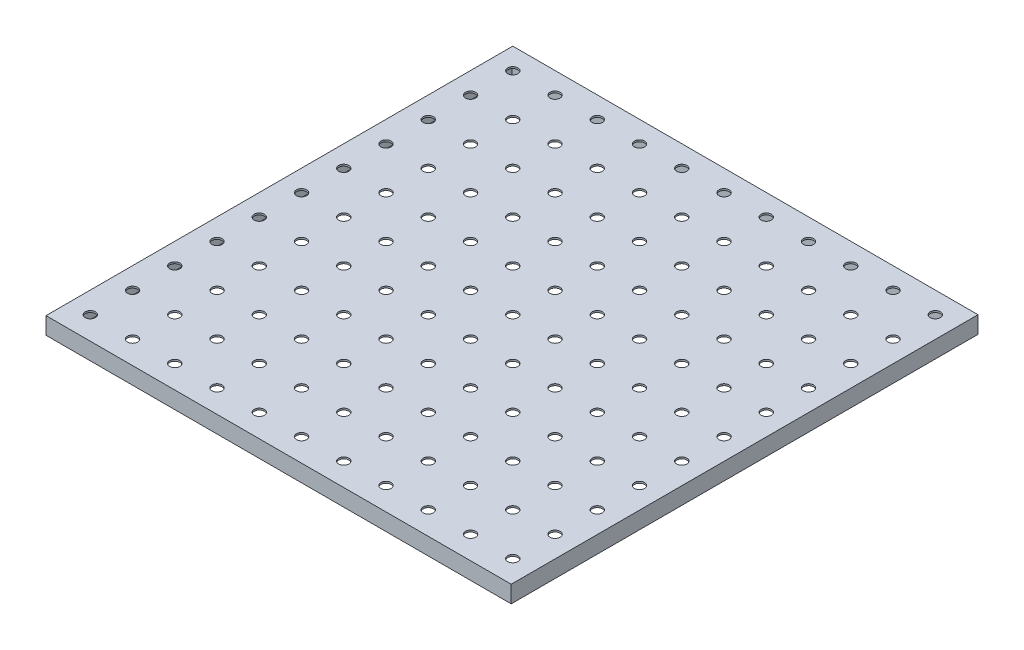
from build123d import *

# Parameters (mm, degrees)
SKETCH1_W           = 273.071306992
SKETCH1_H           = 273.996798624
SKETCH1_R           = 3
BOSS_EXTRUDE1_DEPTH = 10
SKETCH2_W           = 263.071306992
SKETCH2_H           = 263.071306992
CUT_EXTRUDE1_DEPTH  = 9


with BuildPart() as part:
    # Sketch1 → Boss-Extrude1 (new body)
    with BuildSketch(Plane(origin=(0, 0, 0), x_dir=(1, 0, 0), z_dir=(0, 1, 0))):
        Rectangle(SKETCH1_W, SKETCH1_H)
        with Locations((-124.000653496, 124.463399312)):
            Circle(SKETCH1_R, mode=Mode.SUBTRACT)
        with Locations((-99.200653496, 124.463399312)):
            Circle(SKETCH1_R, mode=Mode.SUBTRACT)
        with Locations((-74.400653496, 124.463399312)):
            Circle(SKETCH1_R, mode=Mode.SUBTRACT)
        with Locations((-49.600653496, 124.463399312)):
            Circle(SKETCH1_R, mode=Mode.SUBTRACT)
        with Locations((-24.800653496, 124.463399312)):
            Circle(SKETCH1_R, mode=Mode.SUBTRACT)
        with Locations((-0.000653496, 124.463399312)):
            Circle(SKETCH1_R, mode=Mode.SUBTRACT)
        with Locations((24.799346504, 124.463399312)):
            Circle(SKETCH1_R, mode=Mode.SUBTRACT)
        with Locations((49.599346504, 124.463399312)):
            Circle(SKETCH1_R, mode=Mode.SUBTRACT)
        with Locations((74.399346504, 124.463399312)):
            Circle(SKETCH1_R, mode=Mode.SUBTRACT)
        with Locations((99.199346504, 124.463399312)):
            Circle(SKETCH1_R, mode=Mode.SUBTRACT)
        with Locations((123.999346504, 124.463399312)):
            Circle(SKETCH1_R, mode=Mode.SUBTRACT)
        with Locations((-99.200653496, 99.663399312)):
            Circle(SKETCH1_R, mode=Mode.SUBTRACT)
        with Locations((-74.400653496, 99.663399312)):
            Circle(SKETCH1_R, mode=Mode.SUBTRACT)
        with Locations((-49.600653496, 99.663399312)):
            Circle(SKETCH1_R, mode=Mode.SUBTRACT)
        with Locations((-24.800653496, 99.663399312)):
            Circle(SKETCH1_R, mode=Mode.SUBTRACT)
        with Locations((-0.000653496, 99.663399312)):
            Circle(SKETCH1_R, mode=Mode.SUBTRACT)
        with Locations((24.799346504, 99.663399312)):
            Circle(SKETCH1_R, mode=Mode.SUBTRACT)
        with Locations((49.599346504, 99.663399312)):
            Circle(SKETCH1_R, mode=Mode.SUBTRACT)
        with Locations((74.399346504, 99.663399312)):
            Circle(SKETCH1_R, mode=Mode.SUBTRACT)
        with Locations((99.199346504, 99.663399312)):
            Circle(SKETCH1_R, mode=Mode.SUBTRACT)
        with Locations((123.999346504, 99.663399312)):
            Circle(SKETCH1_R, mode=Mode.SUBTRACT)
        with Locations((-99.200653496, 74.863399312)):
            Circle(SKETCH1_R, mode=Mode.SUBTRACT)
        with Locations((-74.400653496, 74.863399312)):
            Circle(SKETCH1_R, mode=Mode.SUBTRACT)
        with Locations((-49.600653496, 74.863399312)):
            Circle(SKETCH1_R, mode=Mode.SUBTRACT)
        with Locations((-24.800653496, 74.863399312)):
            Circle(SKETCH1_R, mode=Mode.SUBTRACT)
        with Locations((-0.000653496, 74.863399312)):
            Circle(SKETCH1_R, mode=Mode.SUBTRACT)
        with Locations((24.799346504, 74.863399312)):
            Circle(SKETCH1_R, mode=Mode.SUBTRACT)
        with Locations((49.599346504, 74.863399312)):
            Circle(SKETCH1_R, mode=Mode.SUBTRACT)
        with Locations((74.399346504, 74.863399312)):
            Circle(SKETCH1_R, mode=Mode.SUBTRACT)
        with Locations((99.199346504, 74.863399312)):
            Circle(SKETCH1_R, mode=Mode.SUBTRACT)
        with Locations((123.999346504, 74.863399312)):
            Circle(SKETCH1_R, mode=Mode.SUBTRACT)
        with Locations((-99.200653496, 50.063399312)):
            Circle(SKETCH1_R, mode=Mode.SUBTRACT)
        with Locations((-74.400653496, 50.063399312)):
            Circle(SKETCH1_R, mode=Mode.SUBTRACT)
        with Locations((-49.600653496, 50.063399312)):
            Circle(SKETCH1_R, mode=Mode.SUBTRACT)
        with Locations((-24.800653496, 50.063399312)):
            Circle(SKETCH1_R, mode=Mode.SUBTRACT)
        with Locations((-0.000653496, 50.063399312)):
            Circle(SKETCH1_R, mode=Mode.SUBTRACT)
        with Locations((24.799346504, 50.063399312)):
            Circle(SKETCH1_R, mode=Mode.SUBTRACT)
        with Locations((49.599346504, 50.063399312)):
            Circle(SKETCH1_R, mode=Mode.SUBTRACT)
        with Locations((74.399346504, 50.063399312)):
            Circle(SKETCH1_R, mode=Mode.SUBTRACT)
        with Locations((99.199346504, 50.063399312)):
            Circle(SKETCH1_R, mode=Mode.SUBTRACT)
        with Locations((123.999346504, 50.063399312)):
            Circle(SKETCH1_R, mode=Mode.SUBTRACT)
        with Locations((-99.200653496, 25.263399312)):
            Circle(SKETCH1_R, mode=Mode.SUBTRACT)
        with Locations((-74.400653496, 25.263399312)):
            Circle(SKETCH1_R, mode=Mode.SUBTRACT)
        with Locations((-49.600653496, 25.263399312)):
            Circle(SKETCH1_R, mode=Mode.SUBTRACT)
        with Locations((-24.800653496, 25.263399312)):
            Circle(SKETCH1_R, mode=Mode.SUBTRACT)
        with Locations((-0.000653496, 25.263399312)):
            Circle(SKETCH1_R, mode=Mode.SUBTRACT)
        with Locations((24.799346504, 25.263399312)):
            Circle(SKETCH1_R, mode=Mode.SUBTRACT)
        with Locations((49.599346504, 25.263399312)):
            Circle(SKETCH1_R, mode=Mode.SUBTRACT)
        with Locations((74.399346504, 25.263399312)):
            Circle(SKETCH1_R, mode=Mode.SUBTRACT)
        with Locations((99.199346504, 25.263399312)):
            Circle(SKETCH1_R, mode=Mode.SUBTRACT)
        with Locations((123.999346504, 25.263399312)):
            Circle(SKETCH1_R, mode=Mode.SUBTRACT)
        with Locations((-99.200653496, 0.463399312)):
            Circle(SKETCH1_R, mode=Mode.SUBTRACT)
        with Locations((-74.400653496, 0.463399312)):
            Circle(SKETCH1_R, mode=Mode.SUBTRACT)
        with Locations((-49.600653496, 0.463399312)):
            Circle(SKETCH1_R, mode=Mode.SUBTRACT)
        with Locations((-24.800653496, 0.463399312)):
            Circle(SKETCH1_R, mode=Mode.SUBTRACT)
        with Locations((-0.000653496, 0.463399312)):
            Circle(SKETCH1_R, mode=Mode.SUBTRACT)
        with Locations((24.799346504, 0.463399312)):
            Circle(SKETCH1_R, mode=Mode.SUBTRACT)
        with Locations((49.599346504, 0.463399312)):
            Circle(SKETCH1_R, mode=Mode.SUBTRACT)
        with Locations((74.399346504, 0.463399312)):
            Circle(SKETCH1_R, mode=Mode.SUBTRACT)
        with Locations((99.199346504, 0.463399312)):
            Circle(SKETCH1_R, mode=Mode.SUBTRACT)
        with Locations((123.999346504, 0.463399312)):
            Circle(SKETCH1_R, mode=Mode.SUBTRACT)
        with Locations((-99.200653496, -24.336600688)):
            Circle(SKETCH1_R, mode=Mode.SUBTRACT)
        with Locations((-74.400653496, -24.336600688)):
            Circle(SKETCH1_R, mode=Mode.SUBTRACT)
        with Locations((-49.600653496, -24.336600688)):
            Circle(SKETCH1_R, mode=Mode.SUBTRACT)
        with Locations((-24.800653496, -24.336600688)):
            Circle(SKETCH1_R, mode=Mode.SUBTRACT)
        with Locations((-0.000653496, -24.336600688)):
            Circle(SKETCH1_R, mode=Mode.SUBTRACT)
        with Locations((24.799346504, -24.336600688)):
            Circle(SKETCH1_R, mode=Mode.SUBTRACT)
        with Locations((49.599346504, -24.336600688)):
            Circle(SKETCH1_R, mode=Mode.SUBTRACT)
        with Locations((74.399346504, -24.336600688)):
            Circle(SKETCH1_R, mode=Mode.SUBTRACT)
        with Locations((99.199346504, -24.336600688)):
            Circle(SKETCH1_R, mode=Mode.SUBTRACT)
        with Locations((123.999346504, -24.336600688)):
            Circle(SKETCH1_R, mode=Mode.SUBTRACT)
        with Locations((-99.200653496, -49.136600688)):
            Circle(SKETCH1_R, mode=Mode.SUBTRACT)
        with Locations((-74.400653496, -49.136600688)):
            Circle(SKETCH1_R, mode=Mode.SUBTRACT)
        with Locations((-49.600653496, -49.136600688)):
            Circle(SKETCH1_R, mode=Mode.SUBTRACT)
        with Locations((-24.800653496, -49.136600688)):
            Circle(SKETCH1_R, mode=Mode.SUBTRACT)
        with Locations((-0.000653496, -49.136600688)):
            Circle(SKETCH1_R, mode=Mode.SUBTRACT)
        with Locations((24.799346504, -49.136600688)):
            Circle(SKETCH1_R, mode=Mode.SUBTRACT)
        with Locations((49.599346504, -49.136600688)):
            Circle(SKETCH1_R, mode=Mode.SUBTRACT)
        with Locations((74.399346504, -49.136600688)):
            Circle(SKETCH1_R, mode=Mode.SUBTRACT)
        with Locations((99.199346504, -49.136600688)):
            Circle(SKETCH1_R, mode=Mode.SUBTRACT)
        with Locations((123.999346504, -49.136600688)):
            Circle(SKETCH1_R, mode=Mode.SUBTRACT)
        with Locations((-99.200653496, -73.936600688)):
            Circle(SKETCH1_R, mode=Mode.SUBTRACT)
        with Locations((-74.400653496, -73.936600688)):
            Circle(SKETCH1_R, mode=Mode.SUBTRACT)
        with Locations((-49.600653496, -73.936600688)):
            Circle(SKETCH1_R, mode=Mode.SUBTRACT)
        with Locations((-24.800653496, -73.936600688)):
            Circle(SKETCH1_R, mode=Mode.SUBTRACT)
        with Locations((-0.000653496, -73.936600688)):
            Circle(SKETCH1_R, mode=Mode.SUBTRACT)
        with Locations((24.799346504, -73.936600688)):
            Circle(SKETCH1_R, mode=Mode.SUBTRACT)
        with Locations((49.599346504, -73.936600688)):
            Circle(SKETCH1_R, mode=Mode.SUBTRACT)
        with Locations((74.399346504, -73.936600688)):
            Circle(SKETCH1_R, mode=Mode.SUBTRACT)
        with Locations((99.199346504, -73.936600688)):
            Circle(SKETCH1_R, mode=Mode.SUBTRACT)
        with Locations((123.999346504, -73.936600688)):
            Circle(SKETCH1_R, mode=Mode.SUBTRACT)
        with Locations((-99.200653496, -98.736600688)):
            Circle(SKETCH1_R, mode=Mode.SUBTRACT)
        with Locations((-74.400653496, -98.736600688)):
            Circle(SKETCH1_R, mode=Mode.SUBTRACT)
        with Locations((-49.600653496, -98.736600688)):
            Circle(SKETCH1_R, mode=Mode.SUBTRACT)
        with Locations((-24.800653496, -98.736600688)):
            Circle(SKETCH1_R, mode=Mode.SUBTRACT)
        with Locations((-0.000653496, -98.736600688)):
            Circle(SKETCH1_R, mode=Mode.SUBTRACT)
        with Locations((24.799346504, -98.736600688)):
            Circle(SKETCH1_R, mode=Mode.SUBTRACT)
        with Locations((49.599346504, -98.736600688)):
            Circle(SKETCH1_R, mode=Mode.SUBTRACT)
        with Locations((74.399346504, -98.736600688)):
            Circle(SKETCH1_R, mode=Mode.SUBTRACT)
        with Locations((99.199346504, -98.736600688)):
            Circle(SKETCH1_R, mode=Mode.SUBTRACT)
        with Locations((123.999346504, -98.736600688)):
            Circle(SKETCH1_R, mode=Mode.SUBTRACT)
        with Locations((-99.200653496, -123.536600688)):
            Circle(SKETCH1_R, mode=Mode.SUBTRACT)
        with Locations((-74.400653496, -123.536600688)):
            Circle(SKETCH1_R, mode=Mode.SUBTRACT)
        with Locations((-49.600653496, -123.536600688)):
            Circle(SKETCH1_R, mode=Mode.SUBTRACT)
        with Locations((-24.800653496, -123.536600688)):
            Circle(SKETCH1_R, mode=Mode.SUBTRACT)
        with Locations((-0.000653496, -123.536600688)):
            Circle(SKETCH1_R, mode=Mode.SUBTRACT)
        with Locations((24.799346504, -123.536600688)):
            Circle(SKETCH1_R, mode=Mode.SUBTRACT)
        with Locations((49.599346504, -123.536600688)):
            Circle(SKETCH1_R, mode=Mode.SUBTRACT)
        with Locations((74.399346504, -123.536600688)):
            Circle(SKETCH1_R, mode=Mode.SUBTRACT)
        with Locations((99.199346504, -123.536600688)):
            Circle(SKETCH1_R, mode=Mode.SUBTRACT)
        with Locations((123.999346504, -123.536600688)):
            Circle(SKETCH1_R, mode=Mode.SUBTRACT)
        with Locations((-124.000653496, 99.663399312)):
            Circle(SKETCH1_R, mode=Mode.SUBTRACT)
        with Locations((-124.000653496, 74.863399312)):
            Circle(SKETCH1_R, mode=Mode.SUBTRACT)
        with Locations((-124.000653496, 50.063399312)):
            Circle(SKETCH1_R, mode=Mode.SUBTRACT)
        with Locations((-124.000653496, 25.263399312)):
            Circle(SKETCH1_R, mode=Mode.SUBTRACT)
        with Locations((-124.000653496, 0.463399312)):
            Circle(SKETCH1_R, mode=Mode.SUBTRACT)
        with Locations((-124.000653496, -24.336600688)):
            Circle(SKETCH1_R, mode=Mode.SUBTRACT)
        with Locations((-124.000653496, -49.136600688)):
            Circle(SKETCH1_R, mode=Mode.SUBTRACT)
        with Locations((-124.000653496, -73.936600688)):
            Circle(SKETCH1_R, mode=Mode.SUBTRACT)
        with Locations((-124.000653496, -98.736600688)):
            Circle(SKETCH1_R, mode=Mode.SUBTRACT)
        with Locations((-124.000653496, -123.536600688)):
            Circle(SKETCH1_R, mode=Mode.SUBTRACT)
    extrude(amount=BOSS_EXTRUDE1_DEPTH)

    # Sketch2 → Cut-Extrude1 (cut)
    with BuildSketch(Plane.XZ):
        Rectangle(SKETCH2_W, SKETCH2_H)
    extrude(amount=-CUT_EXTRUDE1_DEPTH, mode=Mode.SUBTRACT)


solid = part.part
